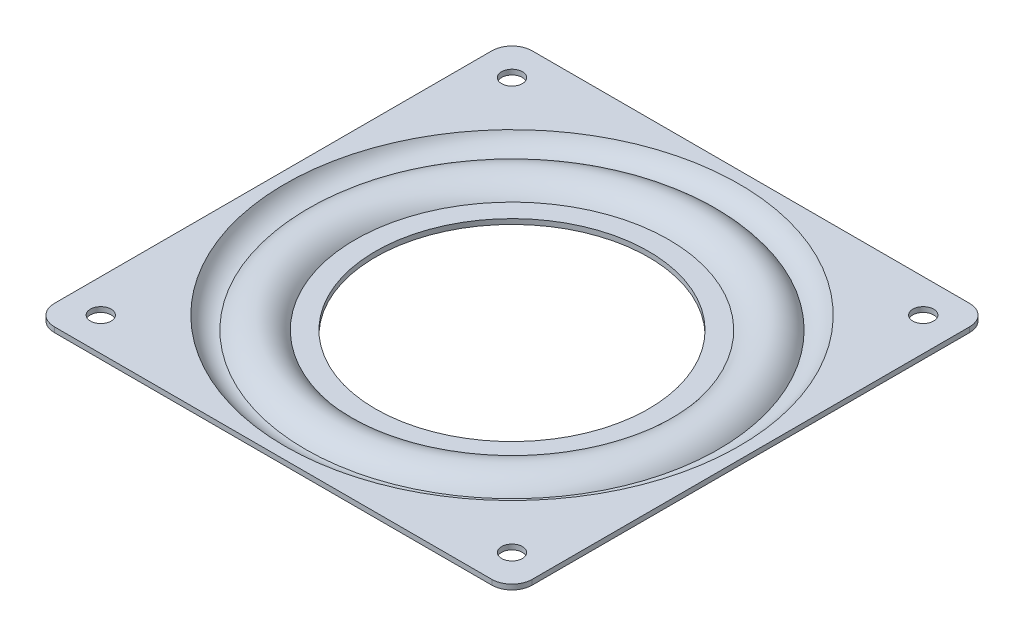
from build123d import *

# Parameters (mm, degrees)
SKETCH_2_R      = 2.05
SKETCH_2_R_2    = 44.910539349
EXTRUDE_1_DEPTH = 1


with BuildPart() as part:
    # 草图1 → 旋转1 (revolve)
    with BuildSketch(Plane.XY):
        with BuildLine():
            ThreePointArc((-45.813874016, -0.428936451), (-43.539426354, -2.86488143), (-40.275857757, -3.540203663))
            ThreePointArc((-40.275857757, -3.540203663), (-35.905809817, -1.000028754), (-31.553091654, -3.569785971))
            Line((-31.553091654, -3.569785971), (-27, -3.569785971))
            Line((-27, -3.569785971), (-27, -2.569785971))
            Line((-27, -2.569785971), (-31, -2.569785971))
            ThreePointArc((-31, -2.569785971), (-35.922766673, 0), (-40.845533346, -2.569785971))
            ThreePointArc((-40.845533346, -2.569785971), (-43.250116145, -1.873465974), (-44.910539349, 0))
            Line((-44.910539349, 0), (-45.813874016, -0.428936451))
        make_face()
    revolve(axis=Axis((0, 6.917160425, 0), (0, -1, 0)))

    # 草图2 → 凸台-拉伸1 (add)
    with BuildSketch(Plane(origin=(0, 0, 0), x_dir=(1, 0, 0), z_dir=(0, 1, 0))):
        with BuildLine():
            Line((43.25, 47.25), (-43.25, 47.25))
            ThreePointArc((-43.25, 47.25), (-46.078427125, 46.078427125), (-47.25, 43.25))
            Line((-47.25, 43.25), (-47.25, -43.25))
            ThreePointArc((-47.25, -43.25), (-46.078427125, -46.078427125), (-43.25, -47.25))
            Line((-43.25, -47.25), (43.25, -47.25))
            ThreePointArc((43.25, -47.25), (46.078427125, -46.078427125), (47.25, -43.25))
            Line((47.25, -43.25), (47.25, 43.25))
            ThreePointArc((47.25, 43.25), (46.078427125, 46.078427125), (43.25, 47.25))
        make_face()
        with Locations((-40.658639918, -40.658639918)):
            Circle(SKETCH_2_R, mode=Mode.SUBTRACT)
        with Locations((40.658639918, -40.658639918)):
            Circle(SKETCH_2_R, mode=Mode.SUBTRACT)
        with Locations((-40.658639918, 40.658639918)):
            Circle(SKETCH_2_R, mode=Mode.SUBTRACT)
        Circle(SKETCH_2_R_2, mode=Mode.SUBTRACT)
        with Locations((40.658639918, 40.658639918)):
            Circle(SKETCH_2_R, mode=Mode.SUBTRACT)
    extrude(amount=-EXTRUDE_1_DEPTH)


solid = part.part
